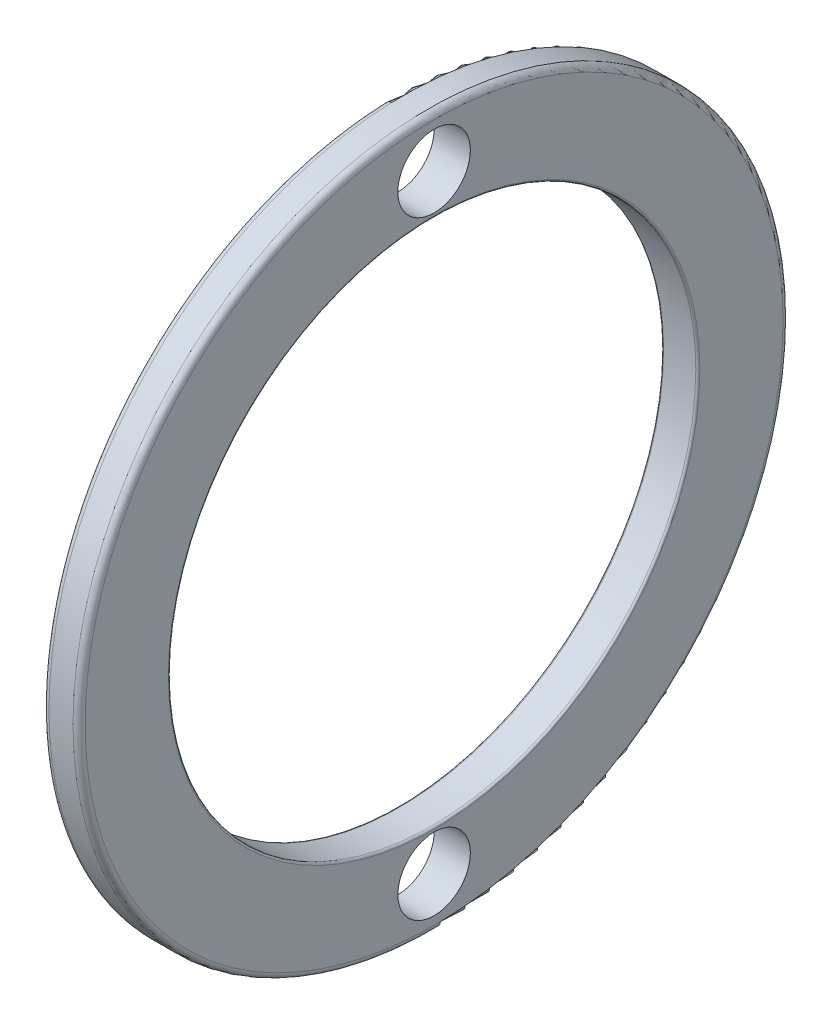
from build123d import *

# Parameters (mm, degrees)
CROQUIS2_R     = 3.572
EXTRUIR1_DEPTH = 12.358
CROQUIS3_R     = 3.572
EXTRUIR2_DEPTH = 12.358


with BuildPart() as part:
    # Croquis1 → Revolución1 (revolve)
    with BuildSketch(Plane.XY):
        with BuildLine():
            Line((5.214, 34.4), (5.214, 26.2))
            ThreePointArc((5.214, 26.2), (5.272578644, 26.058578644), (5.414, 26))
            Line((5.414, 26), (8.586, 26))
            ThreePointArc((8.586, 26), (8.727421356, 26.058578644), (8.786, 26.2))
            Line((8.786, 26.2), (8.786, 34.4))
            ThreePointArc((8.786, 34.4), (8.610264069, 34.824264069), (8.186, 35))
            Line((8.186, 35), (5.814, 35))
            ThreePointArc((5.814, 35), (5.389735931, 34.824264069), (5.214, 34.4))
        make_face()
    revolve(axis=Axis((50, 0, 0), (-1, 0, 0)))

    # Croquis2 → Extruir1 (cut)
    with BuildSketch(Plane(origin=(0, 0, 0), x_dir=(0, 0, -1), z_dir=(1, 0, 0))):
        with Locations((0, 30)):
            Circle(CROQUIS2_R)
    extrude(amount=EXTRUIR1_DEPTH, mode=Mode.SUBTRACT)

    # Croquis3 → Extruir2 (cut)
    with BuildSketch(Plane(origin=(0, 0, 0), x_dir=(0, 0, -1), z_dir=(1, 0, 0))):
        with Locations((0, -30)):
            Circle(CROQUIS3_R)
    extrude(amount=EXTRUIR2_DEPTH, mode=Mode.SUBTRACT)


solid = part.part
